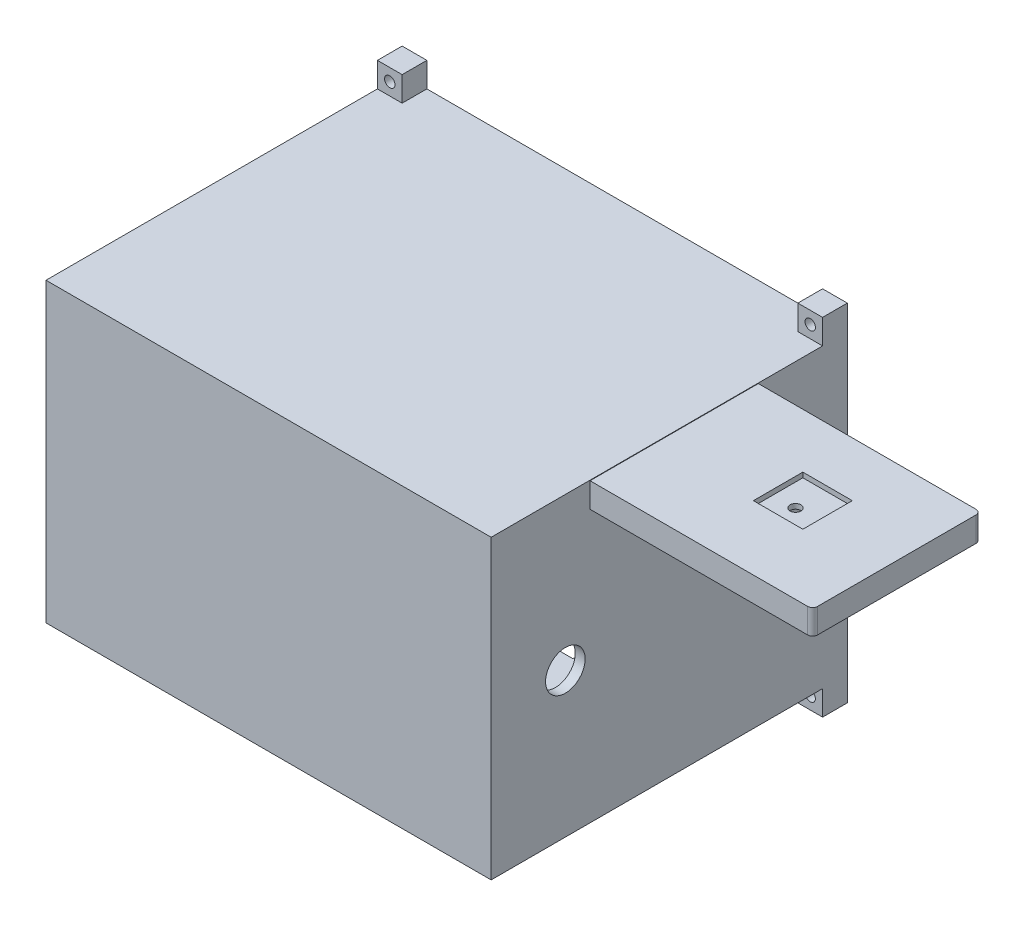
from build123d import *

# Parameters (mm, degrees)
SKETCH_1_W           = 135
SKETCH_1_H           = 60
EXTRUDE_1_DEPTH      = 70
SKETCH_6_W           = 45
SKETCH_6_H           = 70
CUT_EXTRUDE_1_DEPTH  = 0.1
SKETCH_5_W           = 45
SKETCH_5_H           = 70
CUT_EXTRUDE_2_DEPTH  = 54.9
SKETCH_7_W           = 80
SKETCH_7_H           = 50
CUT_EXTRUDE_3_DEPTH  = 75
CUT_EXTRUDE_4_DEPTH  = 6
SKETCH_10_W          = 21.5
SKETCH_10_H          = 15
CUT_EXTRUDE_6_DEPTH  = 10
SKETCH_12_W          = 18.906228009
SKETCH_12_H          = 30.34929214
CUT_EXTRUDE_7_DEPTH  = 50
CUT_EXTRUDE_8_DEPTH  = 3
SKETCH_15_W          = 10
SKETCH_15_H          = 10
CUT_EXTRUDE_9_DEPTH  = 1
SKETCH_17_R          = 1.095275866
CUT_EXTRUDE_11_DEPTH = 7
SKETCH_18_W          = 5
SKETCH_18_H          = 5
SKETCH_18_R          = 1.05
EXTRUDE_2_DEPTH      = 5
SKETCH_19_W          = 90
SKETCH_19_H          = 60
EXTRUDE_3_DEPTH      = 2
SKETCH_20_R          = 4
CUT_EXTRUDE_12_DEPTH = 10
SKETCH_21_W          = 86
SKETCH_21_H          = 56
CUT_EXTRUDE_13_DEPTH = 63
FILLET_3_R           = 1
FILLET_4_R           = 1


with BuildPart() as part:
    # 草圖1 → 填料-伸長1 (new body)
    with BuildSketch(Plane.XY):
        with Locations((-8.008902174, -4.41011236)):
            Rectangle(SKETCH_1_W, SKETCH_1_H)
    extrude(amount=EXTRUDE_1_DEPTH)

    # 草圖6 → 除料-伸長1 (cut)
    with BuildSketch(Plane(origin=(0, 25.58988764, 0), x_dir=(1, 0, 0), z_dir=(0, 1, 0))):
        with Locations((36.991097826, -35)):
            Rectangle(SKETCH_6_W, SKETCH_6_H)
    extrude(amount=-CUT_EXTRUDE_1_DEPTH, mode=Mode.SUBTRACT)

    # 草圖5 → 除料-伸長2 (cut)
    with BuildSketch(Plane.XZ.offset(34.41011236)):
        with Locations((36.991097826, 35)):
            Rectangle(SKETCH_5_W, SKETCH_5_H)
    extrude(amount=-CUT_EXTRUDE_2_DEPTH, mode=Mode.SUBTRACT)

    # 草圖7 → 除料-伸長3 (cut)
    with BuildSketch(Plane.XY):
        with Locations((-30.508902174, -4.41011236)):
            Rectangle(SKETCH_7_W, SKETCH_7_H)
    extrude(amount=CUT_EXTRUDE_3_DEPTH, mode=Mode.SUBTRACT)

    # 草圖8 → 除料-伸長4 (cut)
    with BuildSketch(Plane(origin=(0, 0, 0), x_dir=(-1, 0, 0), z_dir=(0, 0, -1))):
        with BuildLine():
            Line((-13.491097826, 22.58988764), (-13.491097826, -31.41011236))
            ThreePointArc((-13.491097826, -31.41011236), (-12.905311388, -32.824325922), (-11.491097826, -33.41011236))
            Line((-11.491097826, -33.41011236), (72.508902174, -33.41011236))
            ThreePointArc((72.508902174, -33.41011236), (73.923115736, -32.824325922), (74.508902174, -31.41011236))
            Line((74.508902174, -31.41011236), (74.508902174, 22.58988764))
            ThreePointArc((74.508902174, 22.58988764), (73.923115736, 24.004101203), (72.508902174, 24.58988764))
            Line((72.508902174, 24.58988764), (-11.491097826, 24.58988764))
            ThreePointArc((-11.491097826, 24.58988764), (-12.905311388, 24.004101203), (-13.491097826, 22.58988764))
        make_face()
        with BuildLine():
            Line((71.508902174, -28.41011236), (71.508902174, 19.58988764))
            ThreePointArc((71.508902174, 19.58988764), (70.923115736, 21.004101203), (69.508902174, 21.58988764))
            Line((69.508902174, 21.58988764), (-8.491097826, 21.58988764))
            ThreePointArc((-8.491097826, 21.58988764), (-9.905311388, 21.004101203), (-10.491097826, 19.58988764))
            Line((-10.491097826, 19.58988764), (-10.491097826, -28.41011236))
            ThreePointArc((-10.491097826, -28.41011236), (-9.905311388, -29.824325922), (-8.491097826, -30.41011236))
            Line((-8.491097826, -30.41011236), (69.508902174, -30.41011236))
            ThreePointArc((69.508902174, -30.41011236), (70.923115736, -29.824325922), (71.508902174, -28.41011236))
        make_face(mode=Mode.SUBTRACT)
    extrude(amount=-CUT_EXTRUDE_4_DEPTH, mode=Mode.SUBTRACT)

    # 草圖10 → 除料-伸長6 (cut)
    with BuildSketch(Plane(origin=(0, -34.41011236, 0), x_dir=(-1, 0, 0), z_dir=(0, -1, 0))):
        with Locations((24.758902174, -19.5)):
            Rectangle(SKETCH_10_W, SKETCH_10_H)
    extrude(amount=-CUT_EXTRUDE_6_DEPTH, mode=Mode.SUBTRACT)

    # 草圖12 → 除料-伸長7 (cut)
    with BuildSketch(Plane(origin=(14.491097826, 0, 0), x_dir=(0, 0, -1), z_dir=(1, 0, 0))):
        with Locations((-61.464370754, 15.76453371)):
            Rectangle(SKETCH_12_W, SKETCH_12_H)
        with Locations((-8.535629247, 15.76453371)):
            Rectangle(SKETCH_12_W, SKETCH_12_H)
    extrude(amount=CUT_EXTRUDE_7_DEPTH, mode=Mode.SUBTRACT)

    # 草圖14 → 除料-伸長8 (cut)
    with BuildSketch(Plane(origin=(0, 20.48988764, 0), x_dir=(-1, 0, 0), z_dir=(0, -1, 0))):
        with BuildLine():
            Line((-38.126130034, -30.080170747), (-22.017914827, -33))
            ThreePointArc((-22.017914827, -33), (-20.017914827, -35), (-22.017914827, -37))
            Line((-22.017914827, -37), (-38.126130034, -39.919829253))
            ThreePointArc((-38.126130034, -39.919829253), (-39.017914827, -40), (-39.909699621, -39.919829253))
            Line((-39.909699621, -39.919829253), (-56.017914827, -37))
            ThreePointArc((-56.017914827, -37), (-58.017914827, -35), (-56.017914827, -33))
            Line((-56.017914827, -33), (-39.909699621, -30.080170747))
            ThreePointArc((-39.909699621, -30.080170747), (-39.017914827, -30), (-38.126130034, -30.080170747))
        make_face()
    extrude(amount=-CUT_EXTRUDE_8_DEPTH, mode=Mode.SUBTRACT)

    # 草圖15 → 除料-伸長9 (cut)
    with BuildSketch(Plane(origin=(0, 25.48988764, 0), x_dir=(1, 0, 0), z_dir=(0, 1, 0))):
        with Locations((39.491097826, -33.988743251)):
            Rectangle(SKETCH_15_W, SKETCH_15_H)
    extrude(amount=-CUT_EXTRUDE_9_DEPTH, mode=Mode.SUBTRACT)

    # 草圖17 → 除料-伸長11 (cut)
    with BuildSketch(Plane(origin=(0, 20.48988764, 0), x_dir=(-1, 0, 0), z_dir=(0, -1, 0))):
        with Locations((-39.017914827, -35)):
            Circle(SKETCH_17_R)
    extrude(amount=-CUT_EXTRUDE_11_DEPTH, mode=Mode.SUBTRACT)

    # 草圖18 → 填料-伸長2 (add)
    with BuildSketch(Plane.XY):
        with Locations((11.991097826, 28.08988764)):
            Rectangle(SKETCH_18_W, SKETCH_18_H)
        with Locations((11.991097826, 28.08988764)):
            Circle(SKETCH_18_R, mode=Mode.SUBTRACT)
        with Locations((-73.008902174, 28.08988764)):
            Rectangle(SKETCH_18_W, SKETCH_18_H)
        with Locations((-73.008902174, 28.08988764)):
            Circle(SKETCH_18_R, mode=Mode.SUBTRACT)
        with Locations((-73.008902174, -36.91011236)):
            Rectangle(SKETCH_18_W, SKETCH_18_H)
        with Locations((-73.008902174, -36.91011236)):
            Circle(SKETCH_18_R, mode=Mode.SUBTRACT)
        with Locations((11.991097826, -36.91011236)):
            Rectangle(SKETCH_18_W, SKETCH_18_H)
        with Locations((11.991097826, -36.91011236)):
            Circle(SKETCH_18_R, mode=Mode.SUBTRACT)
    extrude(amount=EXTRUDE_2_DEPTH)

    # 草圖19 → 填料-伸長3 (add)
    with BuildSketch(Plane.XY.offset(70)):
        with Locations((-30.508902174, -4.41011236)):
            Rectangle(SKETCH_19_W, SKETCH_19_H)
    extrude(amount=EXTRUDE_3_DEPTH)

    # 草圖20 → 除料-伸長12 (cut)
    with BuildSketch(Plane(origin=(14.491097826, 0, 0), x_dir=(0, 0, -1), z_dir=(1, 0, 0))):
        with Locations((-15, -5.21415213)):
            Circle(SKETCH_20_R)
        with Locations((-57, -5.21415213)):
            Circle(SKETCH_20_R)
    extrude(amount=-CUT_EXTRUDE_12_DEPTH, mode=Mode.SUBTRACT)

    # 草圖21 → 除料-伸長13 (cut)
    with BuildSketch(Plane(origin=(0, 0, 7), x_dir=(-1, 0, 0), z_dir=(0, 0, -1))):
        with Locations((30.508902174, -4.41011236)):
            Rectangle(SKETCH_21_W, SKETCH_21_H)
    extrude(amount=-CUT_EXTRUDE_13_DEPTH, mode=Mode.SUBTRACT)

    # 圓角3
    fillet_3_edges = [part.edges().sort_by_distance(p)[0] for p in [
        (59.491097826, 22.98988764, 17.988743251),
    ]]
    fillet(fillet_3_edges, radius=FILLET_3_R)

    # 圓角4
    fillet_4_edges = [part.edges().sort_by_distance(p)[0] for p in [
        (59.491097826, 22.98988764, 52.011256749),
    ]]
    fillet(fillet_4_edges, radius=FILLET_4_R)


solid = part.part
